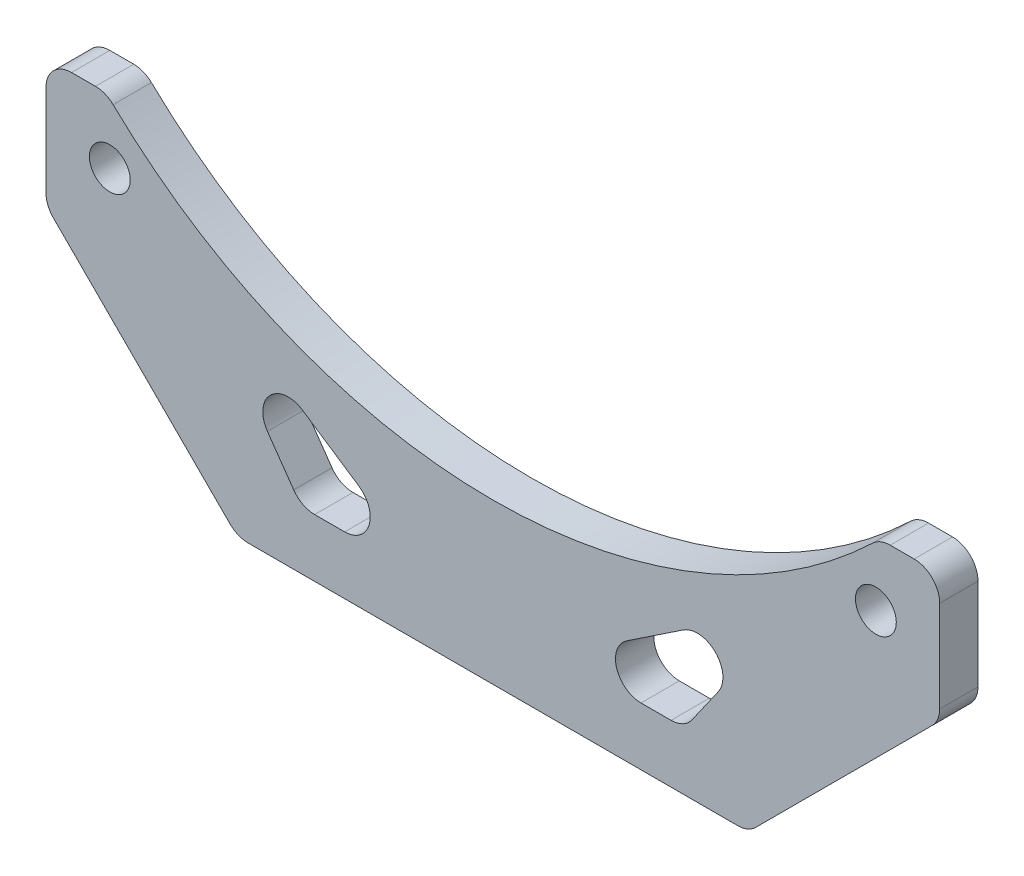
from build123d import *

# Parameters (mm, degrees)
SKETCH_1_R          = 1.6
EXTRUDE_1_DEPTH     = 3
CUT_EXTRUDE_1_DEPTH = 4
SKETCH_4_R          = 43
CUT_EXTRUDE_2_DEPTH = 10
FILLET_1_R          = 2


with BuildPart() as part:
    # 草图1 → 凸台-拉伸1 (new body)
    with BuildSketch(Plane.XY):
        with BuildLine():
            Line((45.024979201, 5), (65, 5))
            Line((65, 5), (65, -5))
            Line((65, -5), (50, -20))
            Line((50, -20), (10, -20))
            Line((10, -20), (-5, -5))
            Line((-5, -5), (-5, 5))
            Line((-5, 5), (14.975020799, 5))
            ThreePointArc((14.975020799, 5), (30, 1.5), (45.024979201, 5))
        make_face()
        with Locations((60, 0)):
            Circle(SKETCH_1_R, mode=Mode.SUBTRACT)
        Circle(SKETCH_1_R, mode=Mode.SUBTRACT)
    extrude(amount=EXTRUDE_1_DEPTH)

    # 草图3 → 切除-拉伸1 (cut, through all)
    with BuildSketch(Plane(origin=(0, 0, 0), x_dir=(-1, 0, 0), z_dir=(0, 0, -1))):
        Polygon((-25, -15.464816242), (-15, -15.464816242), (-6.245134561, -2.961572616), align=None)
        Polygon((-53.754865439, -2.961572616), (-35, -15.464816242), (-45, -15.464816242), align=None)
    extrude(amount=-CUT_EXTRUDE_1_DEPTH, mode=Mode.SUBTRACT)

    # 草图4 → 切除-拉伸2 (cut)
    with BuildSketch(Plane.XY.offset(3)):
        with Locations((30, 35.5)):
            Circle(SKETCH_4_R)
    extrude(amount=-CUT_EXTRUDE_2_DEPTH, mode=Mode.SUBTRACT)

    # 圆角1
    fillet_1_edges = [part.edges().sort_by_distance(p)[0] for p in [
        (50, -20, 1.5),
        (10, -20, 1.5),
        (-5, -5, 1.5),
        (-5, 5, 1.5),
        (65, 5, 1.5),
        (65, -5, 1.5),
        (25, -15.464816242, 1.5),
        (6.245134561, -2.961572616, 1.5),
        (15, -15.464816242, 1.5),
        (45, -15.464816242, 1.5),
        (53.754865439, -2.961572616, 1.5),
        (35, -15.464816242, 1.5),
        (-0.310889132, 5, 1.5),
        (60.310889132, 5, 1.5),
    ]]
    fillet(fillet_1_edges, radius=FILLET_1_R)


solid = part.part
